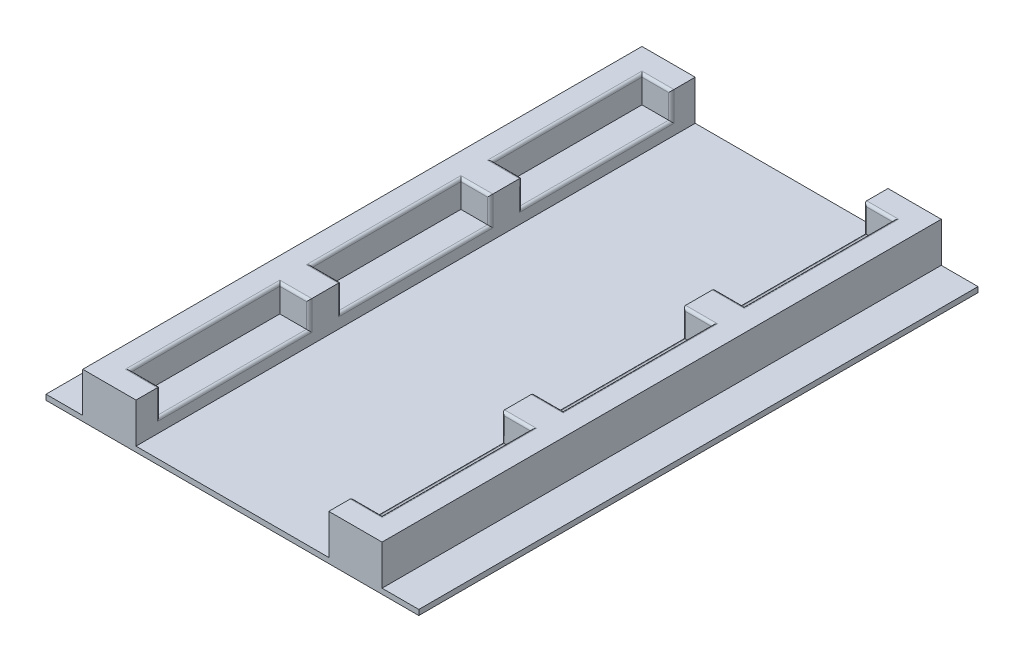
from build123d import *

# Parameters (mm, degrees)
SKIZZE1_W                       = 140
SKIZZE1_H                       = 210
AUFSATZ_LINEAR_AUSTRAGEN1_DEPTH = 2
SKIZZE2_W                       = 20
SKIZZE2_H                       = 210
AUFSATZ_LINEAR_AUSTRAGEN2_DEPTH = 15
SKIZZE3_W                       = 94.4
SKIZZE3_H                       = 56
SCHNITT_LINEAR_AUSTRAGEN1_DEPTH = 10
VERRUNDUNG1_R                   = 1


with BuildPart() as part:
    # Skizze1 → Aufsatz-Linear austragen1 (new body)
    with BuildSketch(Plane(origin=(0, 0, 0), x_dir=(1, 0, 0), z_dir=(0, 1, 0))):
        Rectangle(SKIZZE1_W, SKIZZE1_H)
    extrude(amount=AUFSATZ_LINEAR_AUSTRAGEN1_DEPTH)

    # Skizze2 → Aufsatz-Linear austragen2 (add)
    with BuildSketch(Plane(origin=(0, 2, 0), x_dir=(1, 0, 0), z_dir=(0, 1, 0))):
        with Locations((-46.2, 0)):
            Rectangle(SKIZZE2_W, SKIZZE2_H)
        with Locations((46.2, 0)):
            Rectangle(SKIZZE2_W, SKIZZE2_H)
    extrude(amount=AUFSATZ_LINEAR_AUSTRAGEN2_DEPTH)

    # Skizze3 → Schnitt-Linear austragen1 (cut)
    with BuildSketch(Plane(origin=(0, 17, 0), x_dir=(1, 0, 0), z_dir=(0, 1, 0))):
        Rectangle(SKIZZE3_W, SKIZZE3_H)
        with Locations((0, -68)):
            Rectangle(SKIZZE3_W, SKIZZE3_H)
        with Locations((0, 68)):
            Rectangle(SKIZZE3_W, SKIZZE3_H)
    extrude(amount=-SCHNITT_LINEAR_AUSTRAGEN1_DEPTH, mode=Mode.SUBTRACT)

    # Verrundung1
    verrundung1_edges = [part.edges().sort_by_distance(p)[0] for p in [
        (41.7, 17, 28),
        (41.7, 17, -40),
        (41.7, 17, 96),
        (36.2, 7, 0),
        (36.2, 7, -68),
        (36.2, 7, 68),
        (-36.2, 7, 68),
        (-41.7, 17, 40),
        (-47.2, 17, 68),
        (-41.7, 17, 96),
        (47.2, 17, 68),
        (41.7, 17, 40),
        (-36.2, 12, 96),
        (36.2, 12, 96),
        (-36.2, 12, 40),
        (36.2, 12, 40),
        (-36.2, 7, -68),
        (-41.7, 17, -96),
        (-47.2, 17, -68),
        (-41.7, 17, -40),
        (47.2, 17, -68),
        (41.7, 17, -96),
        (-36.2, 12, -40),
        (36.2, 12, -40),
        (-36.2, 12, -96),
        (36.2, 12, -96),
        (-36.2, 7, 0),
        (-41.7, 17, -28),
        (-47.2, 17, 0),
        (-41.7, 17, 28),
        (47.2, 17, 0),
        (41.7, 17, -28),
        (-36.2, 12, 28),
        (36.2, 12, 28),
        (-36.2, 12, -28),
        (36.2, 12, -28),
    ]]
    fillet(verrundung1_edges, radius=VERRUNDUNG1_R)


solid = part.part
